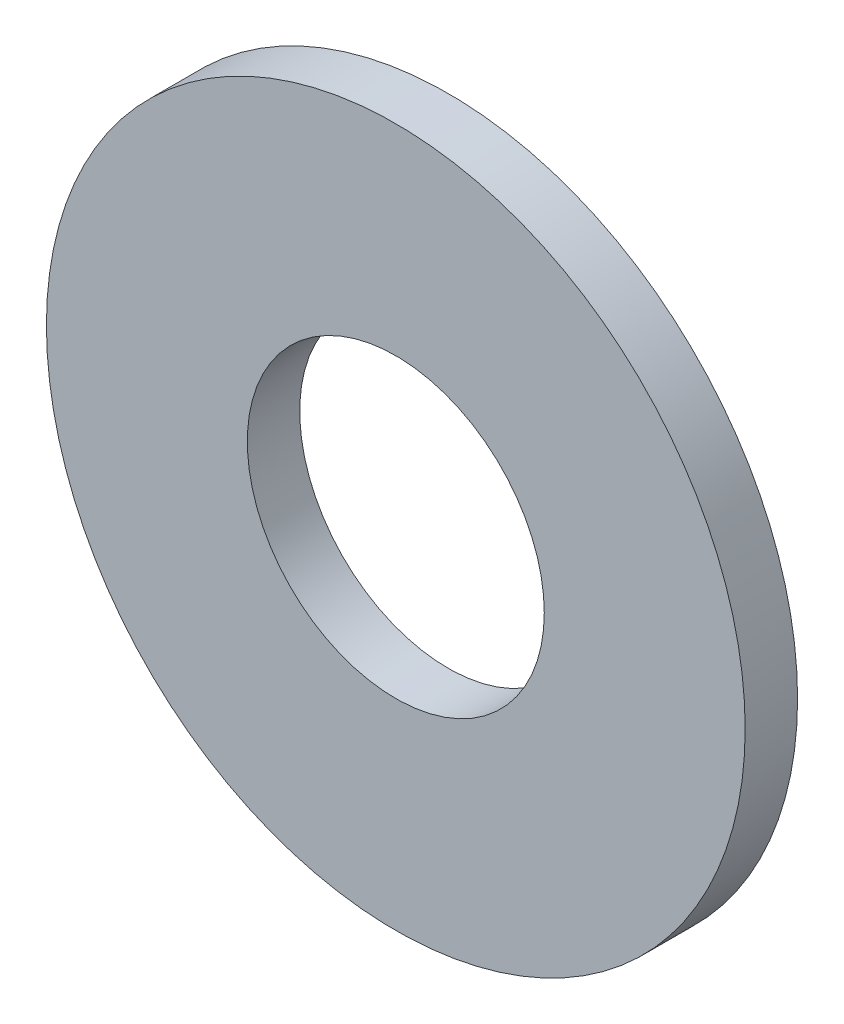
from build123d import *

# Parameters (mm, degrees)
SKETCH1_R           = 4
SKETCH1_R_2         = 1.7
BOSS_EXTRUDE1_DEPTH = 0.6


with BuildPart() as part:
    # Sketch1 → Boss-Extrude1 (new body)
    with BuildSketch(Plane.XY):
        Circle(SKETCH1_R)
        Circle(SKETCH1_R_2, mode=Mode.SUBTRACT)
    extrude(amount=BOSS_EXTRUDE1_DEPTH)


solid = part.part
